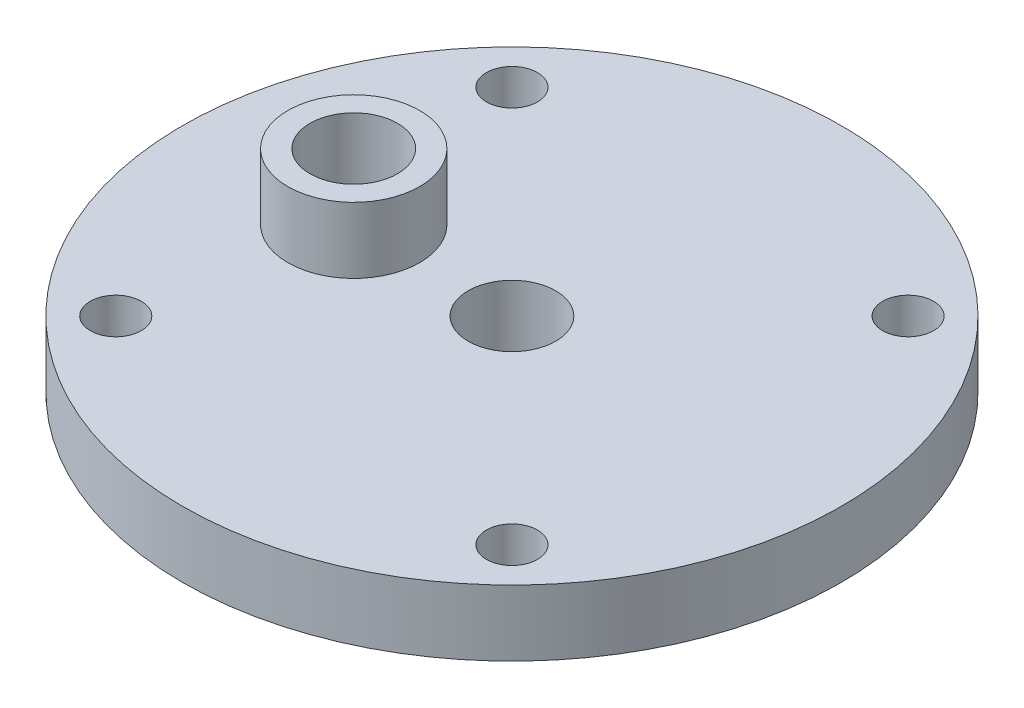
from build123d import *

# Parameters (mm, degrees)
PIPE_TAP_DRILL_FOR_1_8_TAP1_D     = 8.4328
PIPE_TAP_DRILL_FOR_1_8_TAP1_DEPTH = 25.4
PIPE_TAP_DRILL_FOR_1_8_TAP1_TIP   = 2.533468714
CIRPATTERN1_COUNT                 = 4
SKETCH5_R                         = 6.35
BOSS_EXTRUDE1_DEPTH               = 6.35
PIPE_TAP_DRILL_FOR_1_8_TAP2_D     = 8.4328
PIPE_TAP_DRILL_FOR_1_8_TAP2_DEPTH = 6.35
PIPE_TAP_DRILL_FOR_1_8_TAP2_TIP   = 2.533468714
F_1_8_0_125_DIAMETER_HOLE4_D      = 3.175
F_1_8_0_125_DIAMETER_HOLE4_DEPTH  = 14.2875
F_10_0_1935_DIAMETER_HOLE1_D      = 4.9149
F_10_0_1935_DIAMETER_HOLE1_DEPTH  = 6.35
CIRPATTERN2_COUNT                 = 4


with BuildPart() as part:
    # Sketch1 → Revolve1 (revolve)
    with BuildSketch(Plane.XY):
        Polygon((0, 0), (-15.875, 0), (-15.875, 3.175), (-9.525, 3.175), (-9.525, 6.35), (-15.875, 6.35), (-15.875, 7.9375), (-31.75, 7.9375), (-31.75, 14.2875), (0, 14.2875), align=None)
    revolve(axis=Axis((0, 14.2875, 0), (0, -1, 0)))

    # Pipe Tap Drill for 1_8 Tap1
    with Locations(Plane.ZX.offset(14.2875)):
        with Locations((0, 0)):
            Hole(PIPE_TAP_DRILL_FOR_1_8_TAP1_D / 2, depth=PIPE_TAP_DRILL_FOR_1_8_TAP1_DEPTH)
            with Locations((0, 0, -(PIPE_TAP_DRILL_FOR_1_8_TAP1_DEPTH + PIPE_TAP_DRILL_FOR_1_8_TAP1_TIP / 2))):  # 118° drill point
                Cone(0, PIPE_TAP_DRILL_FOR_1_8_TAP1_D / 2, PIPE_TAP_DRILL_FOR_1_8_TAP1_TIP, mode=Mode.SUBTRACT)

    # Sketch3 → Cut-Revolve2 (revolve, cut)
    with BuildSketch(Plane(origin=(0, 0, 0), x_dir=(-1, 0, 0), z_dir=(0, 0, -1))):
        Polygon((-11.388289755, 5.3975), (-11.567894878, 5.217894878), (-4.900394878, -1.449605122), (-4.720789755, -1.27), align=None)
    cut_revolve2 = revolve(axis=Axis((11.567894878, 5.217894878, 0), (-0.707106781, -0.707106781, 0)), mode=Mode.SUBTRACT)

    # CirPattern1: Cut-Revolve2 ×4 about axis
    cirpattern1_axis = Axis((0, 14.2875, 0), (0, 1, 0))
    for i in range(1, CIRPATTERN1_COUNT):
        add(cut_revolve2.rotate(cirpattern1_axis, i * 360 / CIRPATTERN1_COUNT), mode=Mode.SUBTRACT)

    # Sketch5 → Boss-Extrude1 (add)
    with BuildSketch(Plane(origin=(0, 14.2875, 0), x_dir=(1, 0, 0), z_dir=(0, 1, 0))):
        with Locations((-15.24, 0)):
            Circle(SKETCH5_R)
    extrude(amount=BOSS_EXTRUDE1_DEPTH)

    # Pipe Tap Drill for 1_8 Tap2
    with Locations(Plane(origin=(-15.24, 20.6375, 0), x_dir=(0, 0, 1), z_dir=(0, 1, 0))):
        with Locations((0, 0)):
            Hole(PIPE_TAP_DRILL_FOR_1_8_TAP2_D / 2, depth=PIPE_TAP_DRILL_FOR_1_8_TAP2_DEPTH)
            with Locations((0, 0, -(PIPE_TAP_DRILL_FOR_1_8_TAP2_DEPTH + PIPE_TAP_DRILL_FOR_1_8_TAP2_TIP / 2))):  # 118° drill point
                Cone(0, PIPE_TAP_DRILL_FOR_1_8_TAP2_D / 2, PIPE_TAP_DRILL_FOR_1_8_TAP2_TIP, mode=Mode.SUBTRACT)

    # 1_8 _0.125_ Diameter Hole4
    with Locations(Plane(origin=(-15.24, 20.6375, 0), x_dir=(0, 0, 1), z_dir=(0, 1, 0))):
        with Locations((0, 0)):
            Hole(F_1_8_0_125_DIAMETER_HOLE4_D / 2, depth=F_1_8_0_125_DIAMETER_HOLE4_DEPTH)

    # 10 _0.1935_ Diameter Hole1
    with Locations(Plane(origin=(19.083044257, 14.2875, -19.083044257), x_dir=(0, 0, 1), z_dir=(0, 1, 0))):
        with Locations((0, 0)):
            f_10_0_1935_diameter_hole1 = Hole(F_10_0_1935_DIAMETER_HOLE1_D / 2, depth=F_10_0_1935_DIAMETER_HOLE1_DEPTH)

    # CirPattern2: 10 _0.1935_ Diameter Hole1 ×4 about axis
    cirpattern2_axis = Axis((0, 0, 0), (0, 1, 0))
    for i in range(1, CIRPATTERN2_COUNT):
        add(f_10_0_1935_diameter_hole1.rotate(cirpattern2_axis, i * 360 / CIRPATTERN2_COUNT), mode=Mode.SUBTRACT)


solid = part.part
